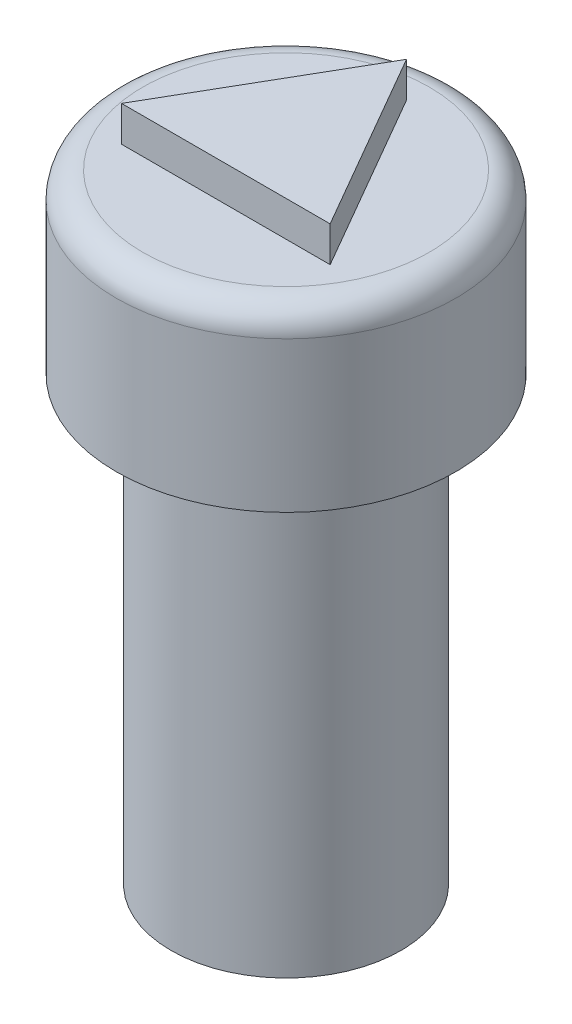
from build123d import *

# Parameters (mm, degrees)
SKETCH1_R           = 3.25
BOSS_EXTRUDE1_DEPTH = 12.5
SKETCH2_R           = 1.75
CUT_EXTRUDE1_DEPTH  = 2.5
SKETCH6_R           = 4.8
BOSS_EXTRUDE2_DEPTH = 5
BOSS_EXTRUDE5_DEPTH = 1
FILLET1_R           = 0.75


with BuildPart() as part:
    # Sketch1 → Boss-Extrude1 (new body)
    with BuildSketch(Plane(origin=(0, 0, 0), x_dir=(1, 0, 0), z_dir=(0, 1, 0))):
        Circle(SKETCH1_R)
    extrude(amount=BOSS_EXTRUDE1_DEPTH)

    # Sketch2 → Cut-Extrude1 (cut)
    with BuildSketch(Plane.XZ):
        Circle(SKETCH2_R)
    extrude(amount=-CUT_EXTRUDE1_DEPTH, mode=Mode.SUBTRACT)

    # Sketch6 → Boss-Extrude2 (add)
    with BuildSketch(Plane(origin=(0, 12.5, 0), x_dir=(1, 0, 0), z_dir=(0, 1, 0))):
        Circle(SKETCH6_R)
    extrude(amount=BOSS_EXTRUDE2_DEPTH)

    # Sketch7 → Boss-Extrude5 (add)
    with BuildSketch(Plane(origin=(0, 17.5, 0), x_dir=(1, 0, 0), z_dir=(0, 1, 0))):
        Polygon((2.95, -1.703183294), (0, 3.406366588), (-2.95, -1.703183294), align=None)
    extrude(amount=BOSS_EXTRUDE5_DEPTH)

    # Fillet1
    fillet1_edges = [part.edges().sort_by_distance(p)[0] for p in [
        (-4.8, 17.5, 0),
    ]]
    fillet(fillet1_edges, radius=FILLET1_R)


solid = part.part
